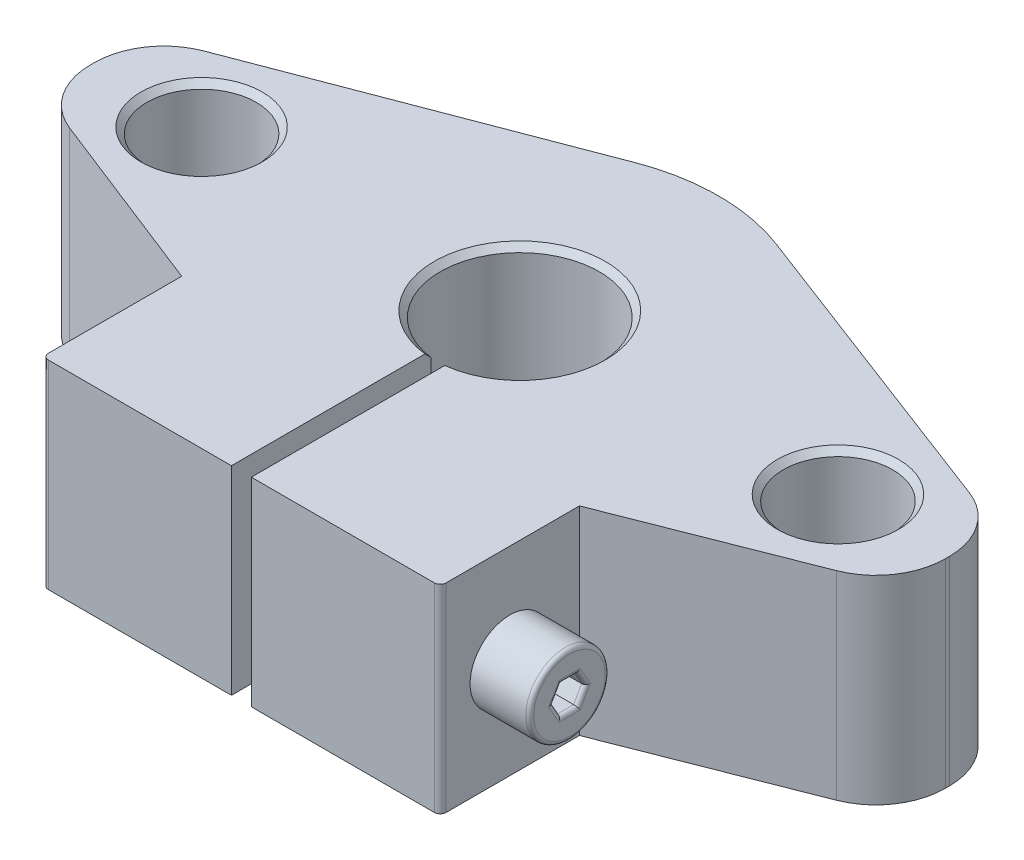
from build123d import *

# Parameters (mm, degrees)
SKETCH1_R                     = 2.75
BOSS_EXTRUDE1_DEPTH           = 10
SKETCH3_R                     = 2
CUT_EXTRUDE1_DEPTH            = 32.5
ESBO_O1_R                     = 2
RESSALTO_EXTRUS_O2_DEPTH      = 13
RESSALTO_EXTRUS_O2_DEPTH_BACK = 3
CORTE_EXTRUS_O1_DEPTH         = 5
FILETE1_R                     = 0.2
FILETE2_R                     = 0.25
CHAMFER_1_SIZE                = 0.3
FILLET_1_R                    = 0.3


with BuildPart() as part:
    # Sketch1 → Boss-Extrude1 (new body)
    with BuildSketch(Plane(origin=(0, 0, 0), x_dir=(1, 0, 0), z_dir=(0, 1, 0))):
        with BuildLine():
            Line((21.5, 0.100660355), (21.5, -0.100660355))
            ThreePointArc((21.5, -0.100660355), (20.891804651, -2.072326113), (19.278590937, -3.35875876))
            Line((19.278590937, -3.35875876), (10, -7))
            Line((10, -7), (10, -14))
            Line((10, -14), (0.5, -14))
            Line((0.5, -14), (0.5, -3.968626967))
            ThreePointArc((0.5, -3.968626967), (0, 4), (-0.5, -3.968626967))
            Line((-0.5, -3.968626967), (-0.5, -14))
            Line((-0.5, -14), (-10, -14))
            Line((-10, -14), (-10, -7))
            Line((-10, -7), (-19.278590937, -3.35875876))
            ThreePointArc((-19.278590937, -3.35875876), (-20.891804651, -2.072326113), (-21.5, -0.100660355))
            Line((-21.5, -0.100660355), (-21.5, 0.100660355))
            ThreePointArc((-21.5, 0.100660355), (-20.881804225, 2.086914218), (-19.245597481, 3.371514512))
            Line((-19.245597481, 3.371514512), (-3.558849946, 9.345297591))
            ThreePointArc((-3.558849946, 9.345297591), (0, 10), (3.558849946, 9.345297591))
            Line((3.558849946, 9.345297591), (19.245597481, 3.371514512))
            ThreePointArc((19.245597481, 3.371514512), (20.881804225, 2.086914218), (21.5, 0.100660355))
        make_face()
        with Locations(Location((-16, 0, 0), (0, 0, 270))):  # turned: the seam where the file's is
            Circle(SKETCH1_R, mode=Mode.SUBTRACT)
        with Locations(Location((16, 0, 0), (0, 0, 270))):  # turned: the seam where the file's is
            Circle(SKETCH1_R, mode=Mode.SUBTRACT)
    extrude(amount=BOSS_EXTRUDE1_DEPTH)

    # Sketch3 → Cut-Extrude1 (cut, through all)
    with BuildSketch(Plane(origin=(10, 0, 0), x_dir=(0, 0, -1), z_dir=(1, 0, 0))):
        with Locations((-10.5, 5)):
            Circle(SKETCH3_R)
    extrude(amount=-CUT_EXTRUDE1_DEPTH, mode=Mode.SUBTRACT)

    # Esboço1 → Ressalto-extrusão2 (add, two sides)
    with BuildSketch(Plane.ZY.offset(-10)) as ressalto_extrus_o2_sk:
        with Locations(Location((10.5, 5, 0), (0, 0, 180))):  # turned: the seam where the file's is
            Circle(ESBO_O1_R)
    extrude(amount=RESSALTO_EXTRUS_O2_DEPTH)
    extrude(ressalto_extrus_o2_sk.sketch, amount=-RESSALTO_EXTRUS_O2_DEPTH_BACK)

    # Esboço2 → Corte-extrusão1 (cut)
    with BuildSketch(Plane.ZY.offset(-13)):
        Polygon((10.90776936, 4.293722751), (11.315538719, 5), (10.90776936, 5.706277249), (10.09223064, 5.706277249), (9.684461281, 5), (10.09223064, 4.293722751), align=None)
    extrude(amount=CORTE_EXTRUS_O1_DEPTH, mode=Mode.SUBTRACT)

    # Filete1
    filete1_edges = [part.edges().sort_by_distance(p)[0] for p in [
        (13, 5, 12.5),
        (13, 4.646861376, 11.11165404),
        (13, 4.293722751, 10.5),
        (13, 4.646861376, 9.88834596),
        (13, 5.353138624, 9.88834596),
        (13, 5.706277249, 10.5),
        (13, 5.353138624, 11.11165404),
    ]]
    fillet(filete1_edges, radius=FILETE1_R)

    # Filete2
    filete2_edges = [part.edges().sort_by_distance(p)[0] for p in [
        (-3, 5, 12.5),
    ]]
    fillet(filete2_edges, radius=FILETE2_R)

    # Фаска1
    chamfer_1_edges = [part.edges().sort_by_distance(p)[0] for p in [
        (0, 0, -4),
        (-16, 0, -2.75),
        (0, 10, -4),
        (-16, 10, -2.75),
        (16, 0, -2.75),
        (16, 10, -2.75),
    ]]
    chamfer(chamfer_1_edges, length=CHAMFER_1_SIZE)

    # Скругление1
    fillet_1_edges = [part.edges().sort_by_distance(p)[0] for p in [
        (10, 5, 14),
        (-10, 5, 14),
    ]]
    fillet(fillet_1_edges, radius=FILLET_1_R)


solid = part.part
